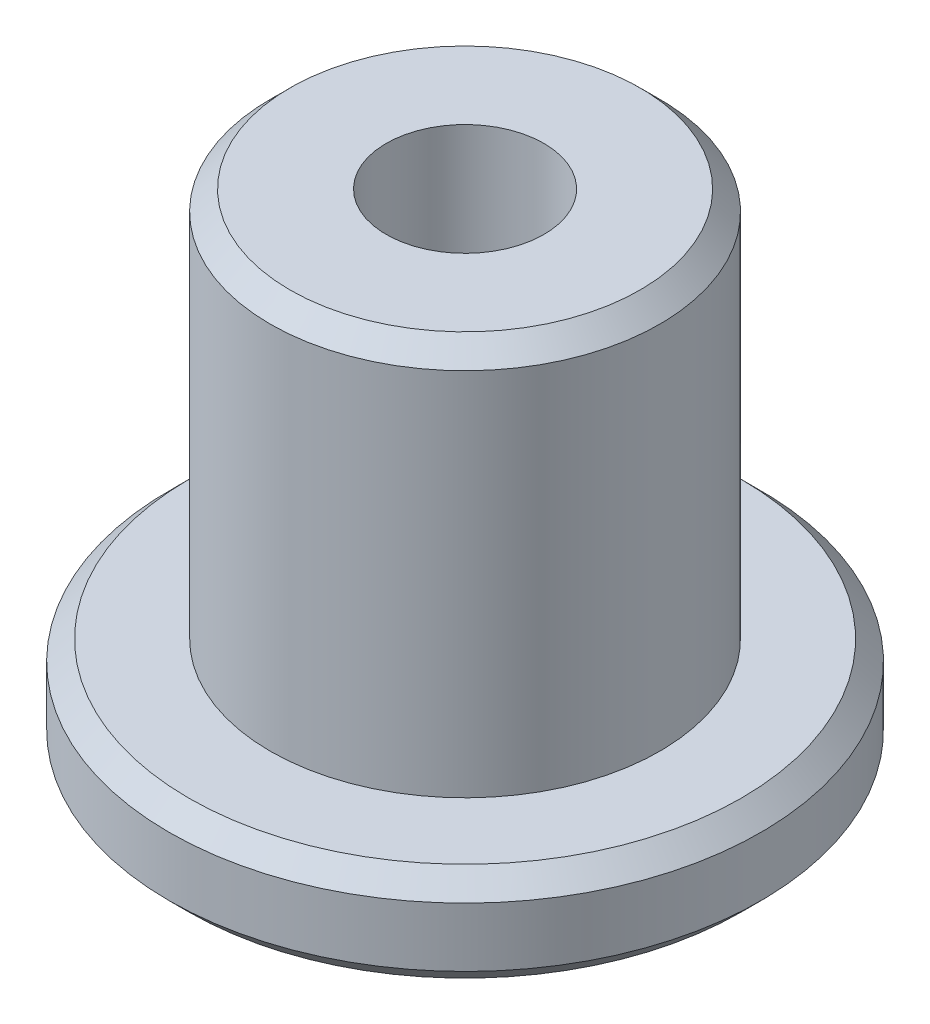
from build123d import *

# Parameters (mm, degrees)
SKETCH1_R                      = 6
BOSS_EXTRUDE1_DEPTH            = 2
SKETCH2_R                      = 3.95
BOSS_EXTRUDE2_DEPTH            = 7.9
CHAMFER1_SIZE                  = 0.4
CBORE_FOR_M3_SHCS1_D           = 3.2
CBORE_FOR_M3_SHCS1_CBORE_D     = 6
CBORE_FOR_M3_SHCS1_CBORE_DEPTH = 2.5


with BuildPart() as part:
    # Sketch1 → Boss-Extrude1 (new body)
    with BuildSketch(Plane(origin=(0, 0, 0), x_dir=(1, 0, 0), z_dir=(0, 1, 0))):
        Circle(SKETCH1_R)
    extrude(amount=BOSS_EXTRUDE1_DEPTH)

    # Sketch2 → Boss-Extrude2 (add)
    with BuildSketch(Plane(origin=(0, 2, 0), x_dir=(1, 0, 0), z_dir=(0, 1, 0))):
        Circle(SKETCH2_R)
    extrude(amount=BOSS_EXTRUDE2_DEPTH)

    # Chamfer1
    chamfer1_edges = [part.edges().sort_by_distance(p)[0] for p in [
        (-6, 0, 0),
        (-6, 2, 0),
        (-3.95, 9.9, 0),
    ]]
    chamfer(chamfer1_edges, length=CHAMFER1_SIZE)

    # CBORE for M3 SHCS1 (through all)
    with Locations(Plane(origin=(0, 0, 0), x_dir=(-1, 0, 0), z_dir=(0, -1, 0))):
        with Locations((0, 0)):
            CounterBoreHole(CBORE_FOR_M3_SHCS1_D / 2, CBORE_FOR_M3_SHCS1_CBORE_D / 2, CBORE_FOR_M3_SHCS1_CBORE_DEPTH)


solid = part.part
